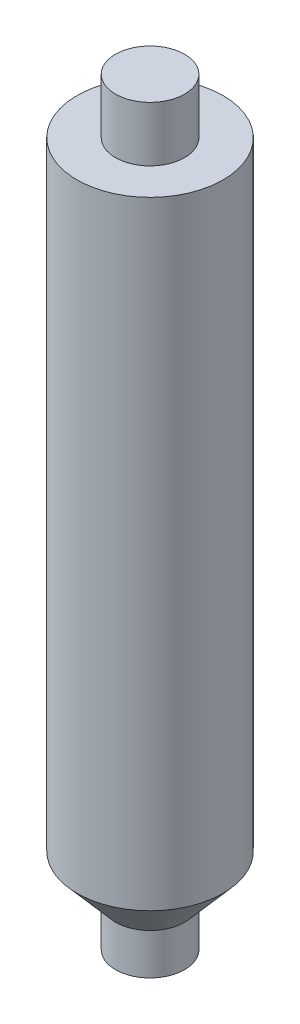
from build123d import *


with BuildPart() as part:
    # Sketch1 → Revolve1 (revolve)
    with BuildSketch(Plane.XY):
        Polygon((0, 0), (0, 70.0000124), (3.188838814, 70.0000124), (3.188838814, 69.0094124), (3.188838814, 64.9200124), (6.7437, 64.9200124), (6.7437, 7.884011277), (3.188838814, 3.794611277), (3.188838814, 0), align=None)
    revolve(axis=Axis((0, 0, 0), (0, 1, 0)))


solid = part.part
